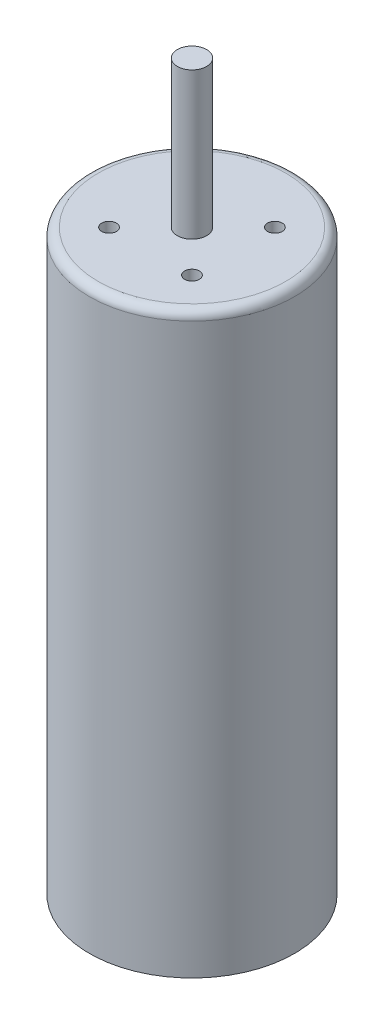
from build123d import *

# Parameters (mm, degrees)
SKETCH_1_R          = 3.5
EXTRUDE_1_DEPTH     = 20
SKETCH_2_R          = 0.5
EXTRUDE_2_DEPTH     = 5
FILLET_1_R          = 0.3
SKETCH_3_R          = 0.25
CUT_EXTRUDE_1_DEPTH = 5
SKETCH_4_OUTSIDE_W  = 14.378
SKETCH_4_OUTSIDE_H  = 14.378
SKETCH_4_OUTSIDE_R  = 3
CUT_EXTRUDE_2_DEPTH = 0.3
SKETCH_5_R          = 0.5
CUT_EXTRUDE_3_DEPTH = 0.3


with BuildPart() as part:
    # 草图1 → 凸台-拉伸1 (new body)
    with BuildSketch(Plane(origin=(0, 0, 0), x_dir=(1, 0, 0), z_dir=(0, 1, 0))):
        Circle(SKETCH_1_R)
    extrude(amount=EXTRUDE_1_DEPTH)

    # 草图2 → 凸台-拉伸2 (add)
    with BuildSketch(Plane(origin=(0, 20, 0), x_dir=(1, 0, 0), z_dir=(0, 1, 0))):
        Circle(SKETCH_2_R)
    extrude(amount=EXTRUDE_2_DEPTH)

    # 圆角1
    fillet_1_edges = [part.edges().sort_by_distance(p)[0] for p in [
        (-3.5, 20, 0),
    ]]
    fillet(fillet_1_edges, radius=FILLET_1_R)

    # 草图3 → 切除-拉伸1 (cut)
    with BuildSketch(Plane(origin=(0, 20, 0), x_dir=(1, 0, 0), z_dir=(0, 1, 0))):
        with Locations((-1.414213562, 1.414213562)):
            Circle(SKETCH_3_R)
        with Locations((1.414213562, 1.414213562)):
            Circle(SKETCH_3_R)
        with Locations((1.414213562, -1.414213562)):
            Circle(SKETCH_3_R)
        with Locations((-1.414213562, -1.414213562)):
            Circle(SKETCH_3_R)
    extrude(amount=-CUT_EXTRUDE_1_DEPTH, mode=Mode.SUBTRACT)

    # 草图4 outside → 切除-拉伸2 (cut)
    with BuildSketch(Plane.XZ):
        Rectangle(SKETCH_4_OUTSIDE_W, SKETCH_4_OUTSIDE_H)
        Circle(SKETCH_4_OUTSIDE_R, mode=Mode.SUBTRACT)
    extrude(amount=-CUT_EXTRUDE_2_DEPTH, mode=Mode.SUBTRACT)

    # 草图5 → 切除-拉伸3 (cut)
    with BuildSketch(Plane.XZ):
        Circle(SKETCH_5_R)
    extrude(amount=-CUT_EXTRUDE_3_DEPTH, mode=Mode.SUBTRACT)


solid = part.part
